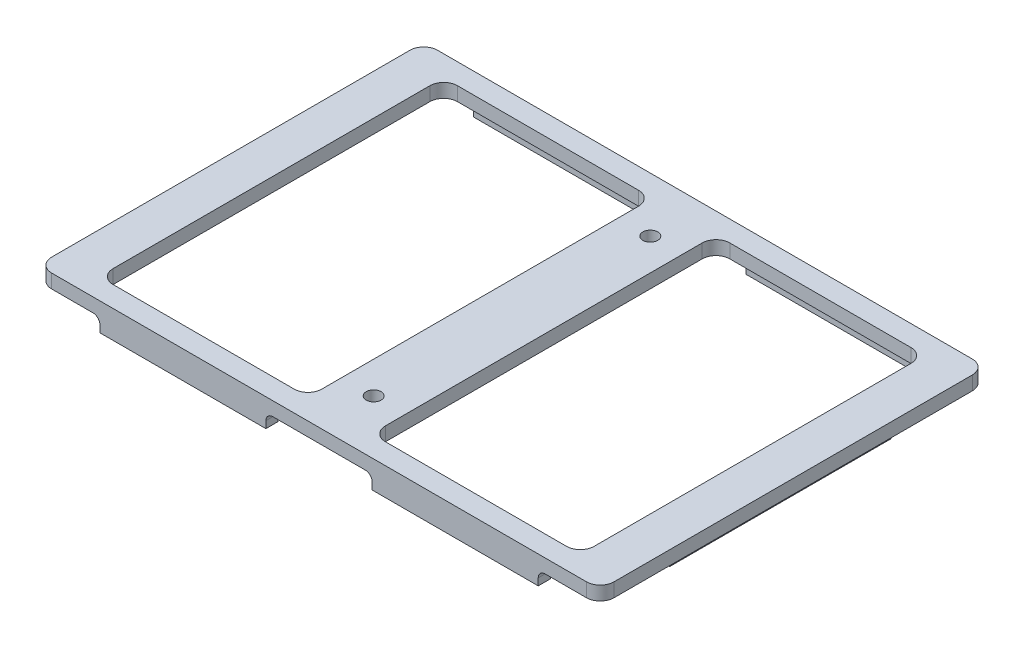
from build123d import *

# Parameters (mm, degrees)
SKETCH1_W            = 129.0828
SKETCH1_H            = 88.5698
BOSS_EXTRUDE1_DEPTH  = 3.175
SKETCH3_W            = 47.9044
SKETCH3_H            = 79.0448
CUT_EXTRUDE1_DEPTH   = 4.175
FILLET1_R            = 3.175
SKETCH5_W            = 38.1
SKETCH5_H            = 2.794
SKETCH5_W_2          = 2.794
SKETCH5_H_2          = 50.8
BOSS_EXTRUDE2_DEPTH  = 3.175
FILLET2_R            = 1.5875
FILLET2_OF_MIRROR1_R = 1.5875
M3_CLEARANCE_HOLE1_D = 3.4


with BuildPart() as part:
    # Sketch1 → Boss-Extrude1 (new body)
    with BuildSketch(Plane(origin=(0, 0, 0), x_dir=(1, 0, 0), z_dir=(0, 1, 0))):
        Rectangle(SKETCH1_W, SKETCH1_H)
    extrude(amount=BOSS_EXTRUDE1_DEPTH)

    # Sketch3 → Cut-Extrude1 (cut, through all)
    with BuildSketch(Plane.XZ):
        with Locations((-31.2547, 0)):
            Rectangle(SKETCH3_W, SKETCH3_H)
        with Locations((31.2547, 0)):
            Rectangle(SKETCH3_W, SKETCH3_H)
    extrude(amount=-CUT_EXTRUDE1_DEPTH, mode=Mode.SUBTRACT)

    # Fillet1
    fillet1_edges = [part.edges().sort_by_distance(p)[0] for p in [
        (-7.3025, 1.5875, -39.5224),
        (-55.2069, 1.5875, -39.5224),
        (-55.2069, 1.5875, 39.5224),
        (-7.3025, 1.5875, 39.5224),
        (55.2069, 1.5875, -39.5224),
        (7.3025, 1.5875, -39.5224),
        (7.3025, 1.5875, 39.5224),
        (55.2069, 1.5875, 39.5224),
        (-64.5414, 1.5875, -44.2849),
        (64.5414, 1.5875, -44.2849),
        (64.5414, 1.5875, 44.2849),
        (-64.5414, 1.5875, 44.2849),
    ]]
    fillet(fillet1_edges, radius=FILLET1_R)

    # Sketch5 → Boss-Extrude2 (add)
    with BuildSketch(Plane.XZ):
        with Locations((-31.2547, 42.8879)):
            Rectangle(SKETCH5_W, SKETCH5_H)
        with Locations((-60.1599, 0)):
            Rectangle(SKETCH5_W_2, SKETCH5_H_2)
        with Locations((-31.2547, -42.8879)):
            Rectangle(SKETCH5_W, SKETCH5_H)
    boss_extrude2 = extrude(amount=BOSS_EXTRUDE2_DEPTH)

    # Fillet2
    fillet2_edges = [part.edges().sort_by_distance(p)[0] for p in [
        (-50.3047, 0, 42.8879),
        (-12.2047, 0, 42.8879),
        (-61.5569, 0, 0),
        (-60.1599, 0, -25.4),
        (-60.1599, 0, 25.4),
        (-50.3047, 0, -42.8879),
        (-12.2047, 0, -42.8879),
    ]]
    fillet(fillet2_edges, radius=FILLET2_R)

    # Mirror1: Boss-Extrude2 across plane
    add(boss_extrude2.mirror(Plane(origin=(0, 0, 0), x_dir=(0, 0, 1), z_dir=(1, 0, 0))))

    # Fillet2 of Mirror1
    fillet2_of_mirror1_edges = [part.edges().sort_by_distance(p)[0] for p in [
        (50.3047, 0, 42.8879),
        (12.2047, 0, 42.8879),
        (61.5569, 0, 0),
        (60.1599, 0, -25.4),
        (60.1599, 0, 25.4),
        (50.3047, 0, -42.8879),
        (12.2047, 0, -42.8879),
    ]]
    fillet(fillet2_of_mirror1_edges, radius=FILLET2_OF_MIRROR1_R)

    # M3 Clearance Hole1 (through all)
    with Locations(Plane(origin=(0, 3.175, 0), x_dir=(1, 0, 0), z_dir=(0, 1, 0))):
        with Locations((0, 31.75), (0, -31.75)):
            Hole(M3_CLEARANCE_HOLE1_D / 2)


solid = part.part
